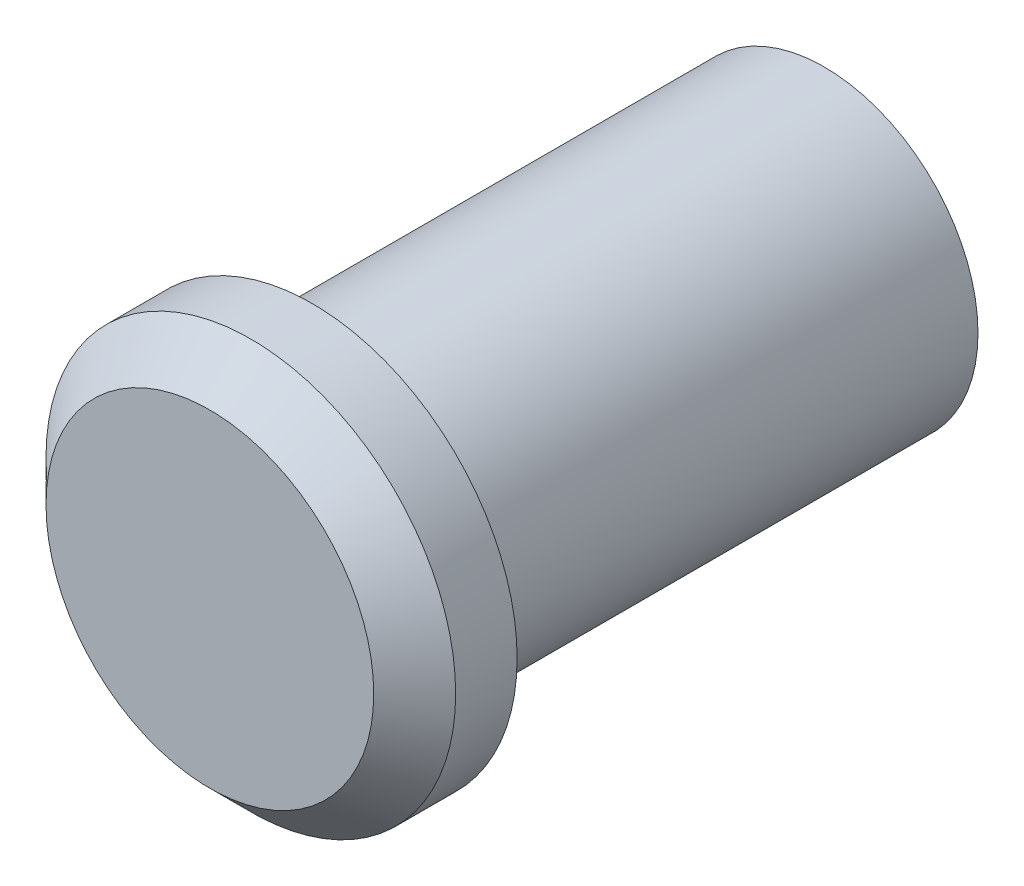
from build123d import *

# Parameters (mm, degrees)
SKETCH1_R           = 7.5
BOSS_EXTRUDE1_DEPTH = 25
SKETCH2_R           = 10
BOSS_EXTRUDE2_DEPTH = 5
SKETCH3_R           = 1.5
CUT_EXTRUDE1_DEPTH  = 5
CHAMFER1_SIZE       = 2


with BuildPart() as part:
    # Sketch1 → Boss-Extrude1 (new body)
    with BuildSketch(Plane.XY):
        Circle(SKETCH1_R)
    extrude(amount=BOSS_EXTRUDE1_DEPTH)

    # Sketch2 → Boss-Extrude2 (add)
    with BuildSketch(Plane.XY.offset(25)):
        Circle(SKETCH2_R)
    extrude(amount=BOSS_EXTRUDE2_DEPTH)

    # Sketch3 → Cut-Extrude1 (cut)
    with BuildSketch(Plane(origin=(0, 0, 0), x_dir=(-1, 0, 0), z_dir=(0, 0, -1))):
        Circle(SKETCH3_R)
    extrude(amount=-CUT_EXTRUDE1_DEPTH, mode=Mode.SUBTRACT)

    # Chamfer1
    chamfer1_edges = [part.edges().sort_by_distance(p)[0] for p in [
        (-10, 0, 30),
    ]]
    chamfer(chamfer1_edges, length=CHAMFER1_SIZE)


solid = part.part
